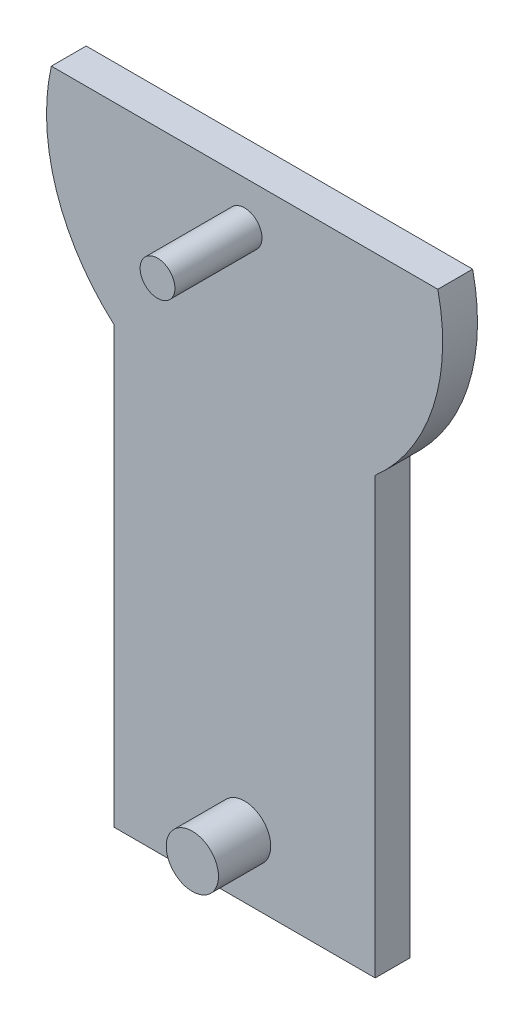
from build123d import *

# Parameters (mm, degrees)
BOSS_EXTRUDE1_DEPTH = 20
BOSS_EXTRUDE2_START = 20
SKETCH1_3_R         = 10
BOSS_EXTRUDE2_DEPTH = 50
SKETCH2_R           = 15
BOSS_EXTRUDE3_DEPTH = 30


with BuildPart() as part:
    # Sketch1 → Boss-Extrude1 (new body)
    with BuildSketch(Plane.XY):
        with BuildLine():
            Line((-75, -335.522292415), (75, -335.522292415))
            Line((75, -335.522292415), (75, -85.522292415))
            ThreePointArc((75, -85.522292415), (108.166019919, -35.201912374), (110.9687456, 25))
            Line((110.9687456, 25), (-110.9687456, 25))
            ThreePointArc((-110.9687456, 25), (-108.166019919, -35.201912374), (-75, -85.522292415))
            Line((-75, -85.522292415), (-75, -335.522292415))
        make_face()
    extrude(amount=BOSS_EXTRUDE1_DEPTH)

    # Sketch1_3 → Boss-Extrude2 (add)
    with BuildSketch(Plane.XY.offset(BOSS_EXTRUDE2_START)):
        Circle(SKETCH1_3_R)
    extrude(amount=BOSS_EXTRUDE2_DEPTH)

    # Sketch2 → Boss-Extrude3 (add)
    with BuildSketch(Plane.XY.offset(20)):
        with Locations((0, -300)):
            Circle(SKETCH2_R)
    extrude(amount=BOSS_EXTRUDE3_DEPTH)


solid = part.part
